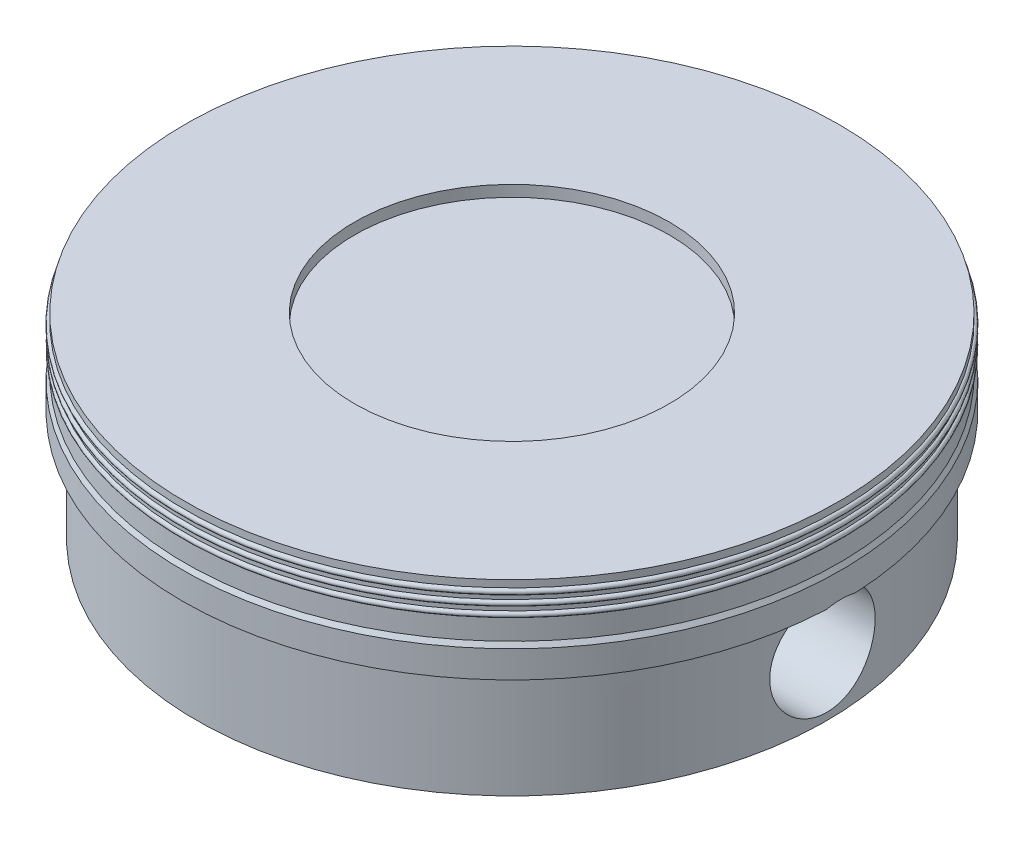
from build123d import *

# Parameters (mm, degrees)
BOSS_EXTRUDE2_DEPTH     = 2.33
SKETCH5_R               = 0.8
CUT_EXTRUDE1_DEPTH      = 6.002314755
CUT_EXTRUDE1_DEPTH_BACK = 6.002314755


with BuildPart() as part:
    # Sketch2 → Revolve1 (revolve)
    with BuildSketch(Plane.XY):
        with BuildLine():
            Line((4.78, 0), (3.43, 0))
            Line((3.43, 0), (3.43, 1.93))
            Line((3.43, 1.93), (4.2, 1.93))
            Line((4.2, 1.93), (4.2, 2.33))
            Line((4.2, 2.33), (0, 2.33))
            Line((0, 2.33), (0, 2.8))
            Line((0, 2.8), (2.39, 2.8))
            Line((2.39, 2.8), (2.39, 2.97))
            Line((2.39, 2.97), (4.96, 2.97))
            Line((4.96, 2.97), (4.96, 2.862314655))
            ThreePointArc((4.96, 2.862314655), (5.002314655, 2.82), (4.96, 2.777685345))
            Line((4.96, 2.777685345), (4.96, 2.71))
            ThreePointArc((4.96, 2.71), (5, 2.67), (4.96, 2.63))
            Line((4.96, 2.63), (4.96, 2.56))
            ThreePointArc((4.96, 2.56), (5, 2.52), (4.96, 2.48))
            Line((4.96, 2.48), (4.96, 2.16))
            Line((4.96, 2.16), (5, 2.09))
            Line((5, 2.09), (5, 1.68))
            Line((5, 1.68), (4.78, 1.68))
            Line((4.78, 1.68), (4.78, 0))
        make_face()
    revolve(axis=Axis((0, 0, 0), (0, 1, 0)))

    # Sketch4 → Boss-Extrude2 (add)
    with BuildSketch(Plane.XZ.offset(-2.33)):
        with BuildLine():
            Line((-1.5, 3.084623154), (-1.5, -3.084623154))
            ThreePointArc((-1.5, -3.084623154), (-3.43, 0), (-1.5, 3.084623154))
        make_face()
        with BuildLine():
            Line((1.5, 3.084623154), (1.5, -3.084623154))
            ThreePointArc((1.5, -3.084623154), (3.43, 0), (1.5, 3.084623154))
        make_face()
    extrude(amount=BOSS_EXTRUDE2_DEPTH)

    # Sketch5 → Cut-Extrude1 (cut, two sides)
    with BuildSketch(Plane(origin=(0, 0, 0), x_dir=(0, 0, -1), z_dir=(1, 0, 0))) as cut_extrude1_sk:
        with Locations((0, 0.91)):
            Circle(SKETCH5_R)
    extrude(amount=CUT_EXTRUDE1_DEPTH, mode=Mode.SUBTRACT)
    extrude(cut_extrude1_sk.sketch, amount=-CUT_EXTRUDE1_DEPTH_BACK, mode=Mode.SUBTRACT)


solid = part.part
